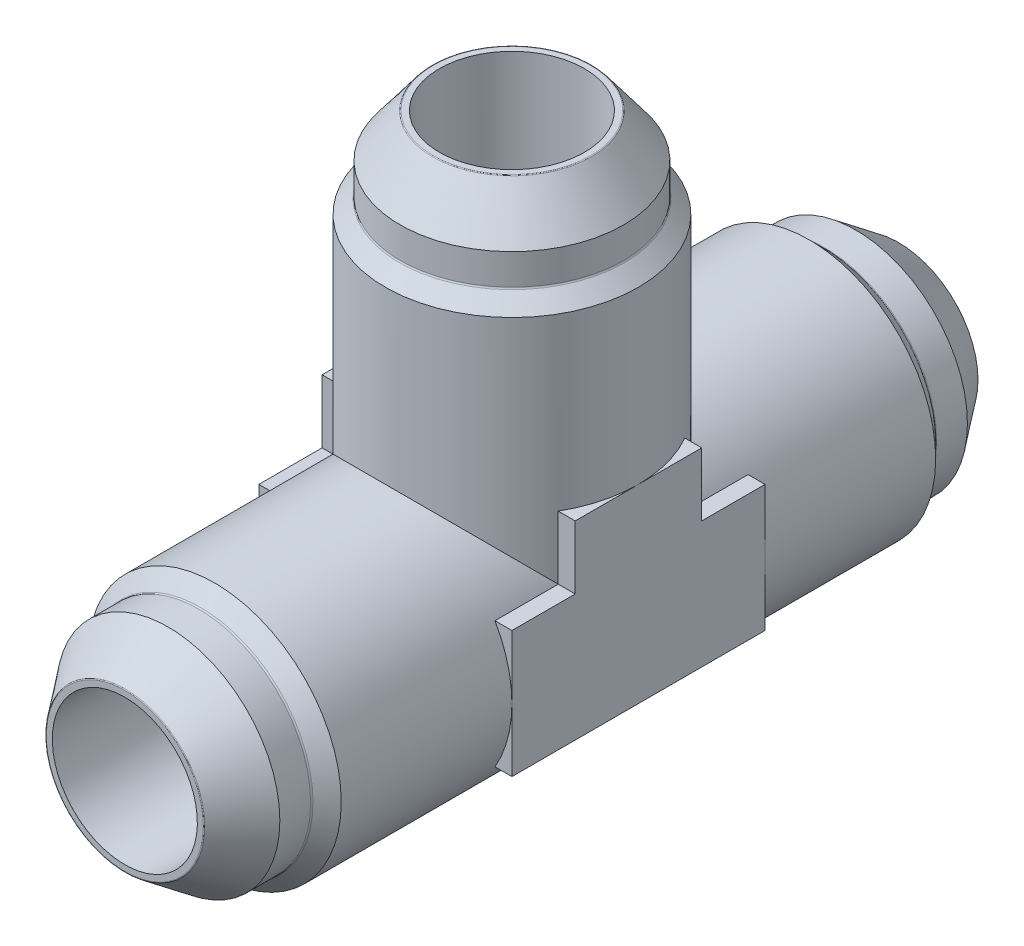
from build123d import *

# Parameters (mm, degrees)
SKETCH4_W           = 19.3294
SKETCH4_H           = 13.49375
CIRPATTERN1_COUNT   = 3
CIRPATTERN1_ANGLE   = 180
BOSS_EXTRUDE1_DEPTH = 13.49375
CIRPATTERN2_COUNT   = 3
CIRPATTERN2_ANGLE   = 180


with BuildPart() as part:
    # Sketch1 → Revolve1 (revolve)
    with BuildSketch(Plane(origin=(0, 0, 0), x_dir=(0, 0, -1), z_dir=(1, 0, 0))):
        with BuildLine():
            Line((-41.275, 0), (-19.3294, 0))
            Line((-19.3294, 0), (-19.3294, 12.0015))
            Line((-19.3294, 12.0015), (-19.3294, 13.49375))
            Line((-19.3294, 13.49375), (-23.99665, 13.49375))
            Line((-23.99665, 13.49375), (-31.69285, 13.49375))
            Line((-31.69285, 13.49375), (-33.199605122, 11.986994878))
            ThreePointArc((-33.199605122, 11.986994878), (-33.282008653, 11.931934599), (-33.379210245, 11.9126))
            Line((-33.379210245, 11.9126), (-36.65714943, 11.9126))
            Line((-36.65714943, 11.9126), (-41.224430508, 8.470906846))
            ThreePointArc((-41.224430508, 8.470906846), (-41.261656664, 8.426147258), (-41.275, 8.369480136))
            Line((-41.275, 8.369480136), (-41.275, 0))
        make_face()
    revolve(axis=Axis((0, 0, 19.812), (0, 0, -1)))

    # Sketch4 → Revolve2 (revolve)
    with BuildSketch(Plane(origin=(0, 0, 0), x_dir=(0, 0, -1), z_dir=(1, 0, 0))):
        with Locations((-9.6647, 6.746875)):
            Rectangle(SKETCH4_W, SKETCH4_H)
    revolve(axis=Axis((0, 0, 0), (0, 0, 1)))


with BuildPart() as cirpattern1_1:
    # CirPattern1: pattern copy
    add(part.part.rotate(Axis((-10.773895932, 0, 0), (-1, 0, 0)), 1 * CIRPATTERN1_ANGLE / (CIRPATTERN1_COUNT - 1)))


with BuildPart() as cirpattern1_2:
    # CirPattern1: pattern copy
    add(part.part.rotate(Axis((-10.773895932, 0, 0), (-1, 0, 0)), 2 * CIRPATTERN1_ANGLE / (CIRPATTERN1_COUNT - 1)))


with BuildPart() as cirpattern1_1_1:
    add(cirpattern1_1.part)

    # Combine1: union CirPattern1_2, part
    add(cirpattern1_2.part)
    add(part.part)

    # Sketch5 → Boss-Extrude1 (add, symmetric)
    with BuildSketch(Plane(origin=(0, 0, 0), x_dir=(0, 0, -1), z_dir=(1, 0, 0))):
        Polygon((-6.746875, 13.49375), (6.746875, 13.49375), (6.746875, 6.746875), (13.49375, 6.746875), (13.49375, -6.746875), (-13.49375, -6.746875), (-13.49375, 6.746875), (-6.746875, 6.746875), align=None)
    extrude(amount=BOSS_EXTRUDE1_DEPTH, both=True)

    # Sketch6 → Cut-Revolve1 (revolve, cut)
    with BuildSketch(Plane(origin=(0, 0, 0), x_dir=(0, 0, -1), z_dir=(1, 0, 0))):
        with BuildLine():
            Line((-41.275, 7.7343), (0, 7.7343))
            ThreePointArc((0, 7.7343), (5.468975978, 5.468975978), (7.7343, 0))
            Line((7.7343, 0), (-41.275, 0))
            Line((-41.275, 0), (-41.275, 7.7343))
        make_face()
    cut_revolve1 = revolve(axis=Axis((0, 0, -7.7343), (0, 0, 1)), mode=Mode.SUBTRACT)

    # CirPattern2: Cut-Revolve1 ×3 about axis
    cirpattern2_axis = Axis((-10.773895932, 0, 0), (-1, 0, 0))
    for i in range(1, CIRPATTERN2_COUNT):
        add(cut_revolve1.rotate(cirpattern2_axis, i * CIRPATTERN2_ANGLE / (CIRPATTERN2_COUNT - 1)), mode=Mode.SUBTRACT)


solid = cirpattern1_1_1.part
